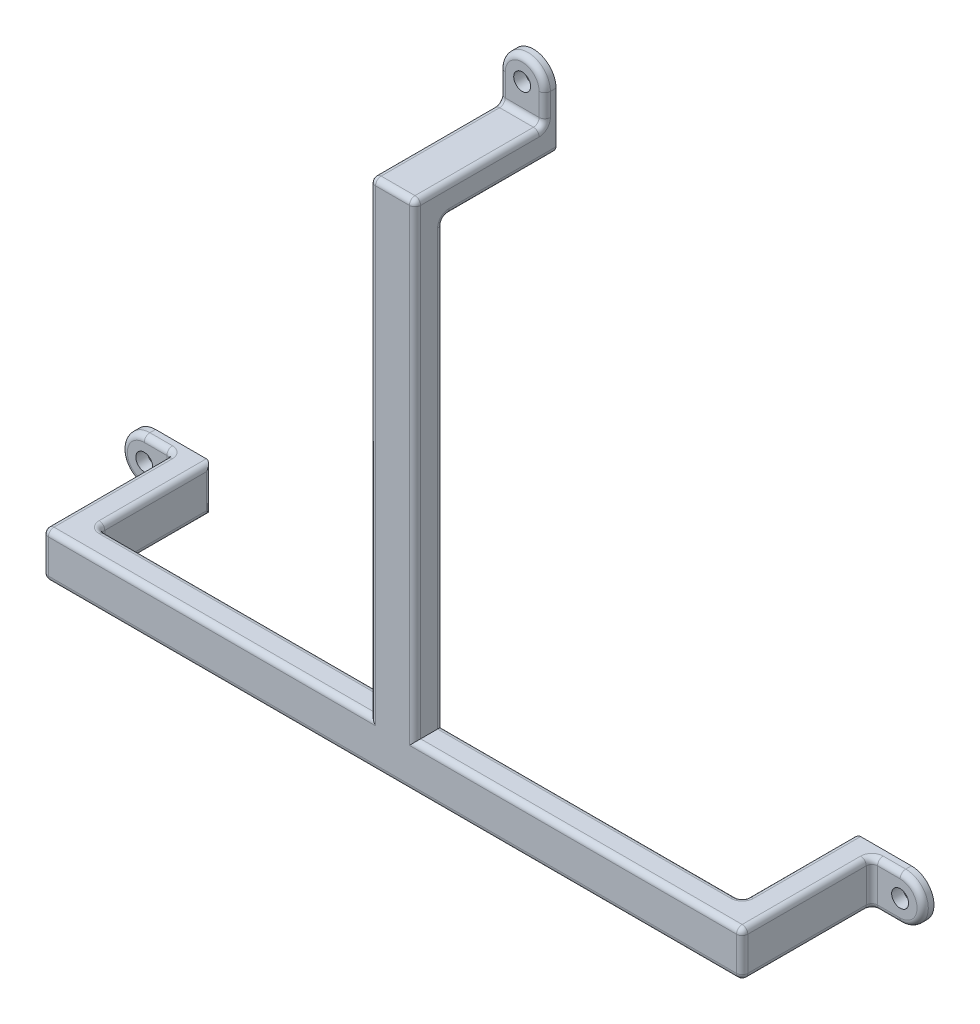
from build123d import *

# Parameters (mm, degrees)
SKETCH2_R             = 1.5
BOSS_EXTRUDE1_DEPTH   = 2
BOSS_EXTRUDE1_2_DEPTH = 2
BOSS_EXTRUDE1_3_DEPTH = 2
SKETCH3_W             = 8
SKETCH3_H             = 5
SKETCH3_W_2           = 5
SKETCH3_H_2           = 8
BOSS_EXTRUDE2_DEPTH   = 23
SKETCH4_W             = 5
SKETCH4_H             = 8
BOSS_EXTRUDE3_DEPTH   = 115
SKETCH5_W             = 8
SKETCH5_H             = 5
BOSS_EXTRUDE4_DEPTH   = 85
FILLET1_R             = 1


with BuildPart() as part:
    # Sketch2 → Boss-Extrude1 (new body)
    with BuildSketch(Plane.XY):
        with BuildLine():
            Line((4, 91.9), (4, 81.9))
            Line((4, 81.9), (-4, 81.9))
            Line((-4, 81.9), (-4, 91.9))
            ThreePointArc((-4, 91.9), (0, 95.9), (4, 91.9))
        make_face()
        with Locations((0, 91.9)):
            Circle(SKETCH2_R, mode=Mode.SUBTRACT)
    extrude(amount=BOSS_EXTRUDE1_DEPTH)



with BuildPart() as body_2:
    # Sketch2 → Boss-Extrude1 2 (new body)
    with BuildSketch(Plane.XY):
        with BuildLine():
            Line((67, -4), (57, -4))
            Line((57, -4), (57, 4))
            Line((57, 4), (67, 4))
            ThreePointArc((67, 4), (71, 0), (67, -4))
        make_face()
        with Locations((67, 0)):
            Circle(SKETCH2_R, mode=Mode.SUBTRACT)
    extrude(amount=BOSS_EXTRUDE1_2_DEPTH)


with BuildPart() as body_3:
    # Sketch2 → Boss-Extrude1 3 (new body)
    with BuildSketch(Plane.XY):
        with BuildLine():
            Line((-67, 4), (-57, 4))
            Line((-57, 4), (-57, -4))
            Line((-57, -4), (-67, -4))
            ThreePointArc((-67, -4), (-71, 0), (-67, 4))
        make_face()
        with Locations((-67, 0)):
            Circle(SKETCH2_R, mode=Mode.SUBTRACT)
    extrude(amount=BOSS_EXTRUDE1_3_DEPTH)


with BuildPart() as part_1:
    add(part.part)

    add(body_2.part)  # Boss-Extrude2 merges body 2

    add(body_3.part)  # Boss-Extrude2 merges body 3
    # Sketch3 → Boss-Extrude2 (add)
    with BuildSketch(Plane.XY.offset(2)):
        with Locations((0, 84.4)):
            Rectangle(SKETCH3_W, SKETCH3_H)
        with Locations((-59.5, 0)):
            Rectangle(SKETCH3_W_2, SKETCH3_H_2)
        with Locations((59.5, 0)):
            Rectangle(SKETCH3_W_2, SKETCH3_H_2)
    extrude(amount=BOSS_EXTRUDE2_DEPTH)

    # Sketch4 → Boss-Extrude3 (add)
    with BuildSketch(Plane.ZY.offset(-57)):
        with Locations((22.5, 0)):
            Rectangle(SKETCH4_W, SKETCH4_H)
    extrude(amount=BOSS_EXTRUDE3_DEPTH)

    # Sketch5 → Boss-Extrude4 (add)
    with BuildSketch(Plane(origin=(0, 81.9, 0), x_dir=(-1, 0, 0), z_dir=(0, -1, 0))):
        with Locations((0, -22.5)):
            Rectangle(SKETCH5_W, SKETCH5_H)
    extrude(amount=BOSS_EXTRUDE4_DEPTH)

    # Fillet1
    fillet1_edges = [part_1.edges().sort_by_distance(p)[0] for p in [
        (4, 89.4, 2),
        (-4, 89.4, 2),
        (0, 86.9, 2),
        (-4, 86.9, 13.5),
        (0, 86.9, 25),
        (4, 86.9, 13.5),
        (-4, 45.45, 25),
        (0, 95.9, 2),
        (0, 81.9, 0),
        (4, 81.9, 10),
        (-4, 81.9, 10),
        (0, 81.9, 20),
        (4, 42.95, 20),
        (-4, 42.95, 20),
        (4, 45.45, 25),
        (-57, 4, 10),
        (-64.5, 4, 2),
        (-57, 0, 20),
        (-57, -4, 10),
        (-71, 0, 2),
        (-57, 0, 0),
        (0, -4, 20),
        (57, -4, 10),
        (64.5, -4, 2),
        (0, -4, 25),
        (-62, -4, 13.5),
        (-64.5, -4, 2),
        (62, 4, 13.5),
        (64.5, 4, 2),
        (-62, 0, 2),
        (-62, 4, 13.5),
        (-33, 4, 25),
        (-62, 0, 25),
        (33, 4, 25),
        (30.5, 4, 20),
        (57, 0, 20),
        (-30.5, 4, 20),
        (57, 4, 10),
        (62, 0, 2),
        (71, 0, 2),
        (57, 0, 0),
        (62, 0, 25),
        (62, -4, 13.5),
    ]]
    fillet(fillet1_edges, radius=FILLET1_R)


solid = part_1.part
